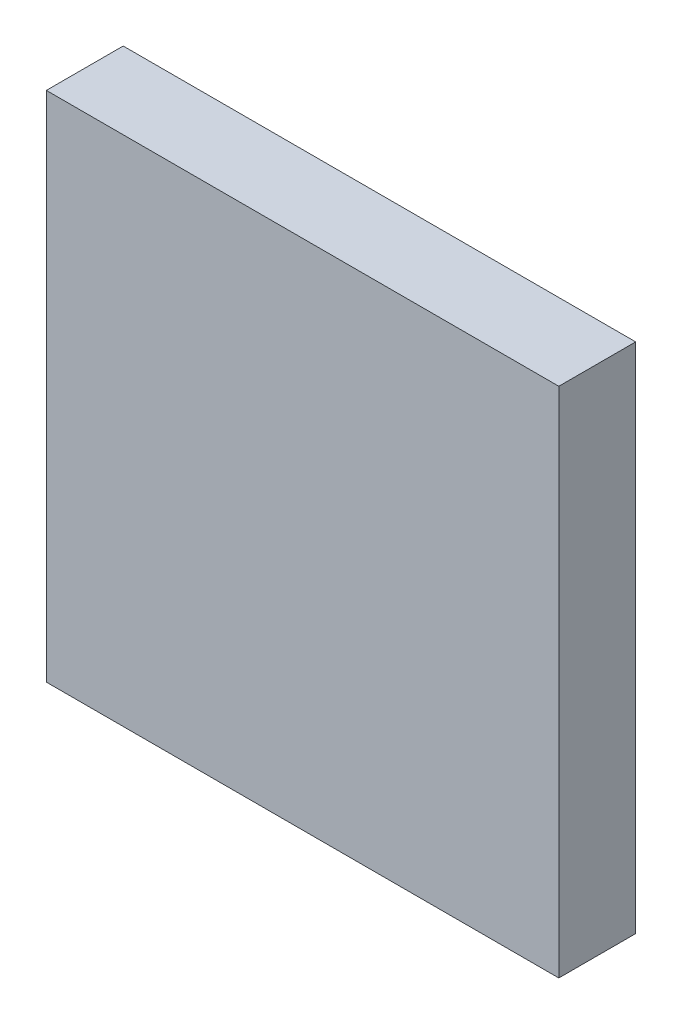
from build123d import *

# Parameters (mm, degrees)
SKETCH1_W           = 20
SKETCH1_H           = 20
BOSS_EXTRUDE1_DEPTH = 3


with BuildPart() as part:
    # Sketch1 → Boss-Extrude1 (new body)
    with BuildSketch(Plane.XY):
        with Locations((10, 10)):
            Rectangle(SKETCH1_W, SKETCH1_H)
    extrude(amount=BOSS_EXTRUDE1_DEPTH)


solid = part.part
